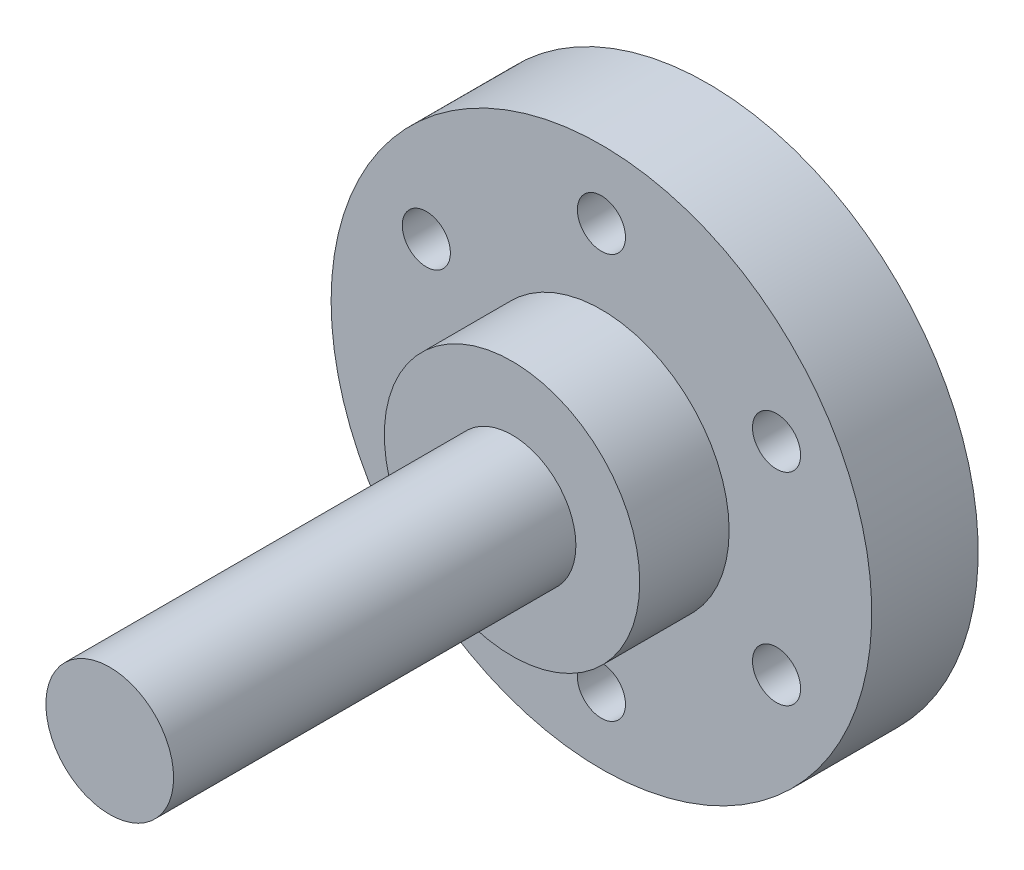
from build123d import *

# Parameters (mm, degrees)
SKETCH1_R                 = 3
BOSS_EXTRUDE1_DEPTH       = 29
SKETCH2_R                 = 6
BOSS_EXTRUDE2_DEPTH       = 2.1
SKETCH3_R                 = 12.7
BOSS_EXTRUDE3_DEPTH       = 5
SKETCH4_R                 = 6
BOSS_EXTRUDE4_DEPTH       = 2.1
F_4_40_TAPPED_HOLE1_D     = 2.2606
F_4_40_TAPPED_HOLE1_DEPTH = 7.6
F_4_40_TAPPED_HOLE1_TIP   = 0.679152758


with BuildPart() as part:
    # Sketch1 → Boss-Extrude1 (new body)
    with BuildSketch(Plane.XY):
        Circle(SKETCH1_R)
    extrude(amount=BOSS_EXTRUDE1_DEPTH)

    # Sketch2 → Boss-Extrude2 (add)
    with BuildSketch(Plane.XY.offset(8)):
        Circle(SKETCH2_R)
    extrude(amount=-BOSS_EXTRUDE2_DEPTH)

    # Sketch3 → Boss-Extrude3 (add)
    with BuildSketch(Plane(origin=(0, 0, 5.9), x_dir=(-1, 0, 0), z_dir=(0, 0, -1))):
        Circle(SKETCH3_R)
    extrude(amount=BOSS_EXTRUDE3_DEPTH)

    # Sketch4 → Boss-Extrude4 (add)
    with BuildSketch(Plane.XY.offset(8)):
        Circle(SKETCH4_R)
    extrude(amount=BOSS_EXTRUDE4_DEPTH)

    # #4-40 Tapped Hole1
    with Locations(Plane(origin=(0, 0, 0.9), x_dir=(-1, 0, 0), z_dir=(0, 0, -1))):
        with Locations((8.227241336, 4.75), (8.227241336, -4.75), (0, -9.5), (-8.227241336, -4.75), (-8.227241336, 4.75), (0, 9.5)):
            Hole(F_4_40_TAPPED_HOLE1_D / 2, depth=F_4_40_TAPPED_HOLE1_DEPTH)
            with Locations((0, 0, -(F_4_40_TAPPED_HOLE1_DEPTH + F_4_40_TAPPED_HOLE1_TIP / 2))):  # 118° drill point
                Cone(0, F_4_40_TAPPED_HOLE1_D / 2, F_4_40_TAPPED_HOLE1_TIP, mode=Mode.SUBTRACT)


solid = part.part
